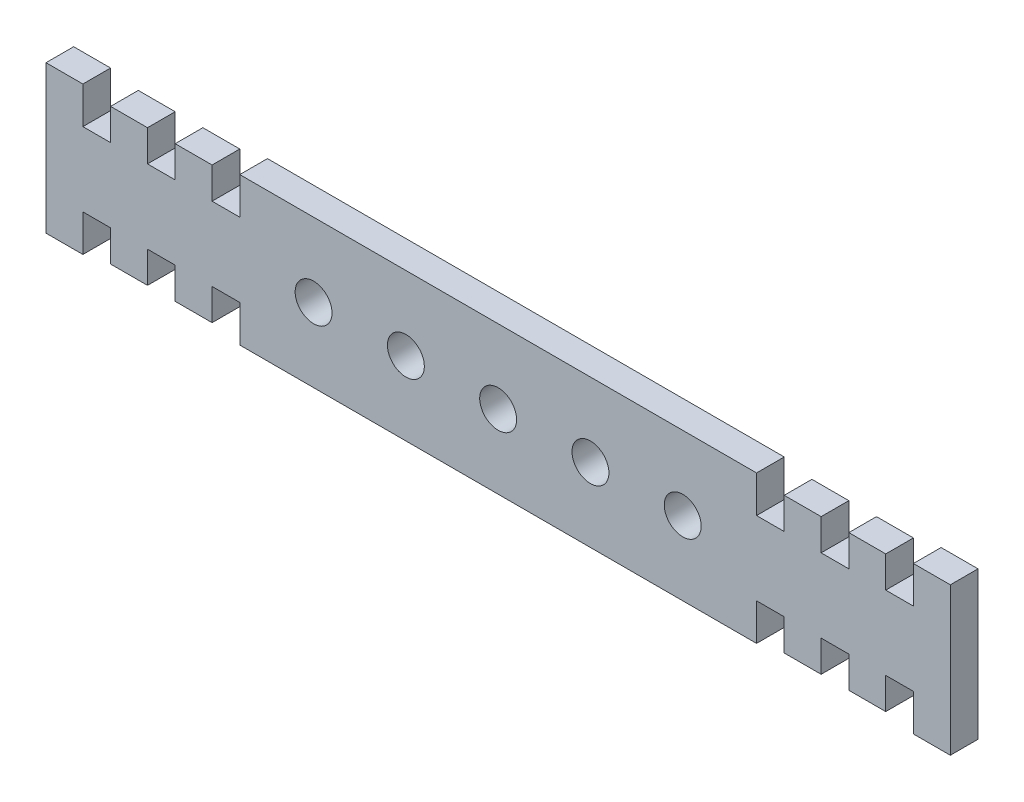
from build123d import *

# Parameters (mm, degrees)
SKETCH_1_R      = 1
EXTRUDE_1_DEPTH = 1.5


with BuildPart() as part:
    # 草图1 → 凸台-拉伸1 (new body)
    with BuildSketch(Plane.XY):
        Polygon((-14.124024572, 4.643948243), (13.876451621, 4.643948243), (13.875975428, 2.643948243), (15.375975428, 2.643948243), (15.375975428, 4.343948243), (17.375975428, 4.343948243), (17.375975428, 2.643948243), (18.875975428, 2.643948243), (18.875499235, 4.343948243), (20.875975428, 4.343948243), (20.875499235, 2.643948243), (22.375975428, 2.643948243), (22.375023042, 4.643948243), (24.375023042, 4.643948243), (24.375023042, -3.356051757), (22.375975428, -3.356051757), (22.375975428, -1.356051757), (20.875499235, -1.356051757), (20.875975428, -3.056051757), (18.875499235, -3.056051757), (18.875975428, -1.356051757), (17.375975428, -1.356051757), (17.375975428, -3.056051757), (15.375975428, -3.056051757), (15.375975428, -1.356051757), (13.875975428, -1.356051757), (13.876451621, -3.356051757), (-14.124024572, -3.356051757), (-14.124024572, -1.356051757), (-15.624024572, -1.356051757), (-15.624024572, -3.056051757), (-17.624024572, -3.056051757), (-17.624024572, -1.356051757), (-19.124024572, -1.356051757), (-19.123548379, -3.056051757), (-21.124024572, -3.056051757), (-21.123548379, -1.356051757), (-22.624024572, -1.356051757), (-22.623072186, -3.356051757), (-24.623072186, -3.356051757), (-24.623072186, 4.643948243), (-22.624024572, 4.643948243), (-22.624024572, 2.643948243), (-21.123548379, 2.643948243), (-21.124024572, 4.343948243), (-19.123548379, 4.343948243), (-19.124024572, 2.643948243), (-17.624024572, 2.643948243), (-17.624024572, 4.343948243), (-15.624024572, 4.343948243), (-15.624024572, 2.643948243), (-14.124024572, 2.643948243), align=None)
        with Locations((-0.124024572, 0.643948243)):
            Circle(SKETCH_1_R, mode=Mode.SUBTRACT)
        with Locations((4.875975428, 0.643948243)):
            Circle(SKETCH_1_R, mode=Mode.SUBTRACT)
        with Locations((9.875975428, 0.643948243)):
            Circle(SKETCH_1_R, mode=Mode.SUBTRACT)
        with Locations((-5.124024572, 0.643948243)):
            Circle(SKETCH_1_R, mode=Mode.SUBTRACT)
        with Locations((-10.124024572, 0.643948243)):
            Circle(SKETCH_1_R, mode=Mode.SUBTRACT)
    extrude(amount=EXTRUDE_1_DEPTH)


solid = part.part
